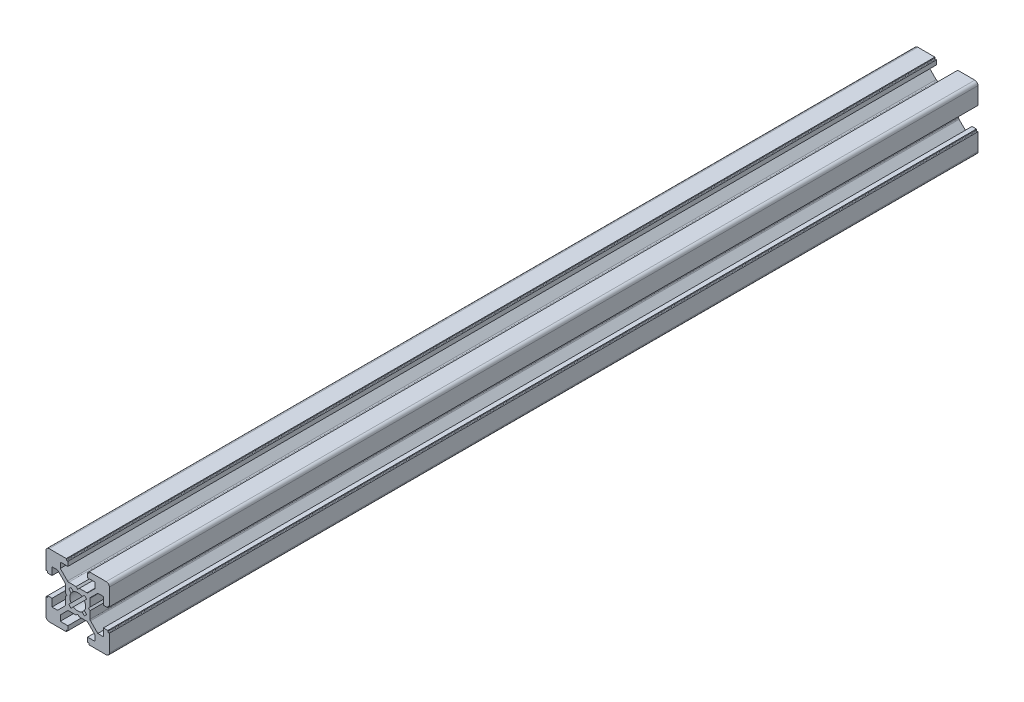
from build123d import *

# Parameters (mm, degrees)
EXTRUDE1_DEPTH = 274


with BuildPart() as part:
    # Sketch1 → Extrude1 (new body)
    with BuildSketch(Plane.XY):
        with BuildLine():
            Line((0, 3.4), (-0.5, 3.9))
            Line((-0.5, 3.9), (-2.844365081, 3.9))
            ThreePointArc((-2.844365081, 3.9), (-3.035706798, 3.938060234), (-3.197918472, 4.046446609))
            Line((-3.197918472, 4.046446609), (-5.5, 6.348528137))
            Line((-5.5, 6.348528137), (-5.5, 8.1))
            Line((-5.5, 8.1), (-3.1, 8.1))
            Line((-3.1, 8.1), (-3.1, 9.5))
            Line((-3.1, 9.5), (-3.4, 9.5))
            ThreePointArc((-3.4, 9.5), (-3.541421356, 9.558578644), (-3.6, 9.7))
            Line((-3.6, 9.7), (-3.6, 10))
            Line((-3.6, 10), (-9, 10))
            ThreePointArc((-9, 10), (-9.707106781, 9.707106781), (-10, 9))
            Line((-10, 9), (-10, 3.6))
            Line((-10, 3.6), (-9.7, 3.6))
            ThreePointArc((-9.7, 3.6), (-9.558578644, 3.541421356), (-9.5, 3.4))
            Line((-9.5, 3.4), (-9.5, 3.1))
            Line((-9.5, 3.1), (-8.1, 3.1))
            Line((-8.1, 3.1), (-8.1, 5.5))
            Line((-8.1, 5.5), (-6.348528137, 5.5))
            Line((-6.348528137, 5.5), (-4.046446609, 3.197918472))
            ThreePointArc((-4.046446609, 3.197918472), (-3.938060234, 3.035706798), (-3.9, 2.844365081))
            Line((-3.9, 2.844365081), (-3.9, 0.5))
            Line((-3.9, 0.5), (-3.4, 0))
            Line((-3.4, 0), (-3.9, -0.5))
            Line((-3.9, -0.5), (-3.9, -2.844365081))
            ThreePointArc((-3.9, -2.844365081), (-3.938060234, -3.035706798), (-4.046446609, -3.197918472))
            Line((-4.046446609, -3.197918472), (-6.348528137, -5.5))
            Line((-6.348528137, -5.5), (-8.1, -5.5))
            Line((-8.1, -5.5), (-8.1, -3.1))
            Line((-8.1, -3.1), (-9.5, -3.1))
            Line((-9.5, -3.1), (-9.5, -3.4))
            ThreePointArc((-9.5, -3.4), (-9.558578644, -3.541421356), (-9.7, -3.6))
            Line((-9.7, -3.6), (-10, -3.6))
            Line((-10, -3.6), (-10, -9))
            ThreePointArc((-10, -9), (-9.707106781, -9.707106781), (-9, -10))
            Line((-9, -10), (-3.6, -10))
            Line((-3.6, -10), (-3.6, -9.7))
            ThreePointArc((-3.6, -9.7), (-3.541421356, -9.558578644), (-3.4, -9.5))
            Line((-3.4, -9.5), (-3.1, -9.5))
            Line((-3.1, -9.5), (-3.1, -8.1))
            Line((-3.1, -8.1), (-5.5, -8.1))
            Line((-5.5, -8.1), (-5.5, -6.348528137))
            Line((-5.5, -6.348528137), (-3.197918472, -4.046446609))
            ThreePointArc((-3.197918472, -4.046446609), (-3.035706798, -3.938060234), (-2.844365081, -3.9))
            Line((-2.844365081, -3.9), (-0.5, -3.9))
            Line((-0.5, -3.9), (0, -3.4))
            Line((0, -3.4), (0.5, -3.9))
            Line((0.5, -3.9), (2.844365081, -3.9))
            ThreePointArc((2.844365081, -3.9), (3.035706798, -3.938060234), (3.197918472, -4.046446609))
            Line((3.197918472, -4.046446609), (5.5, -6.348528137))
            Line((5.5, -6.348528137), (5.5, -8.1))
            Line((5.5, -8.1), (3.1, -8.1))
            Line((3.1, -8.1), (3.1, -9.5))
            Line((3.1, -9.5), (3.4, -9.5))
            ThreePointArc((3.4, -9.5), (3.541421356, -9.558578644), (3.6, -9.7))
            Line((3.6, -9.7), (3.6, -10))
            Line((3.6, -10), (9, -10))
            ThreePointArc((9, -10), (9.707106781, -9.707106781), (10, -9))
            Line((10, -9), (10, -3.6))
            Line((10, -3.6), (9.7, -3.6))
            ThreePointArc((9.7, -3.6), (9.558578644, -3.541421356), (9.5, -3.4))
            Line((9.5, -3.4), (9.5, -3.1))
            Line((9.5, -3.1), (8.1, -3.1))
            Line((8.1, -3.1), (8.1, -5.5))
            Line((8.1, -5.5), (6.348528137, -5.5))
            Line((6.348528137, -5.5), (4.046446609, -3.197918472))
            ThreePointArc((4.046446609, -3.197918472), (3.938060234, -3.035706798), (3.9, -2.844365081))
            Line((3.9, -2.844365081), (3.9, -0.5))
            Line((3.9, -0.5), (3.4, 0))
            Line((3.4, 0), (3.9, 0.5))
            Line((3.9, 0.5), (3.9, 2.844365081))
            ThreePointArc((3.9, 2.844365081), (3.938060234, 3.035706798), (4.046446609, 3.197918472))
            Line((4.046446609, 3.197918472), (6.348528137, 5.5))
            Line((6.348528137, 5.5), (8.1, 5.5))
            Line((8.1, 5.5), (8.1, 3.1))
            Line((8.1, 3.1), (9.5, 3.1))
            Line((9.5, 3.1), (9.5, 3.4))
            ThreePointArc((9.5, 3.4), (9.558578644, 3.541421356), (9.7, 3.6))
            Line((9.7, 3.6), (10, 3.6))
            Line((10, 3.6), (10, 9))
            ThreePointArc((10, 9), (9.707106781, 9.707106781), (9, 10))
            Line((9, 10), (3.6, 10))
            Line((3.6, 10), (3.6, 9.7))
            ThreePointArc((3.6, 9.7), (3.541421356, 9.558578644), (3.4, 9.5))
            Line((3.4, 9.5), (3.1, 9.5))
            Line((3.1, 9.5), (3.1, 8.1))
            Line((3.1, 8.1), (5.5, 8.1))
            Line((5.5, 8.1), (5.5, 6.348528137))
            Line((5.5, 6.348528137), (3.197918472, 4.046446609))
            ThreePointArc((3.197918472, 4.046446609), (3.035706798, 3.938060234), (2.844365081, 3.9))
            Line((2.844365081, 3.9), (0.5, 3.9))
            Line((0.5, 3.9), (0, 3.4))
        make_face()
        with BuildLine():
            ThreePointArc((2.5, 0), (2.394160656, -0.719718523), (2.085604198, -1.378497417))
            Line((2.085604198, -1.378497417), (2.828427125, -2.121320344))
            Line((2.828427125, -2.121320344), (2.121320344, -2.828427125))
            Line((2.121320344, -2.828427125), (1.378497417, -2.085604198))
            ThreePointArc((1.378497417, -2.085604198), (0, -2.5), (-1.378497417, -2.085604198))
            Line((-1.378497417, -2.085604198), (-2.121320344, -2.828427125))
            Line((-2.121320344, -2.828427125), (-2.828427125, -2.121320344))
            Line((-2.828427125, -2.121320344), (-2.085604198, -1.378497417))
            ThreePointArc((-2.085604198, -1.378497417), (-2.5, 0), (-2.085604198, 1.378497417))
            Line((-2.085604198, 1.378497417), (-2.828427125, 2.121320344))
            Line((-2.828427125, 2.121320344), (-2.121320344, 2.828427125))
            Line((-2.121320344, 2.828427125), (-1.378497417, 2.085604198))
            ThreePointArc((-1.378497417, 2.085604198), (0, 2.5), (1.378497417, 2.085604198))
            Line((1.378497417, 2.085604198), (2.121320344, 2.828427125))
            Line((2.121320344, 2.828427125), (2.828427125, 2.121320344))
            Line((2.828427125, 2.121320344), (2.085604198, 1.378497417))
            ThreePointArc((2.085604198, 1.378497417), (2.394160656, 0.719718523), (2.5, 0))
        make_face(mode=Mode.SUBTRACT)
    extrude(amount=EXTRUDE1_DEPTH)


solid = part.part
